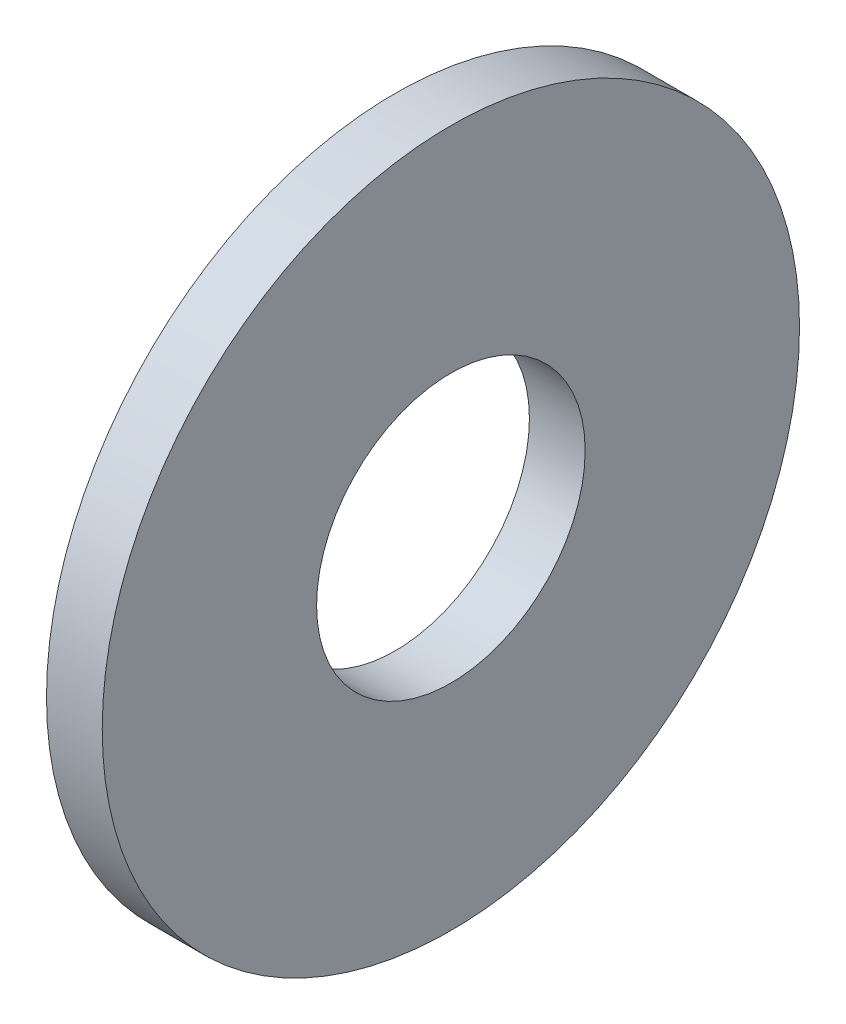
from build123d import *

# Parameters (mm, degrees)
SKETCH1_R           = 8.7376
SKETCH1_R_2         = 3.3655
BOSS_EXTRUDE1_DEPTH = 1.397


with BuildPart() as part:
    # Sketch1 → Boss-Extrude1 (new body)
    with BuildSketch(Plane(origin=(0, 0, 0), x_dir=(0, 0, -1), z_dir=(1, 0, 0))):
        Circle(SKETCH1_R)
        Circle(SKETCH1_R_2, mode=Mode.SUBTRACT)
    extrude(amount=BOSS_EXTRUDE1_DEPTH)


solid = part.part
